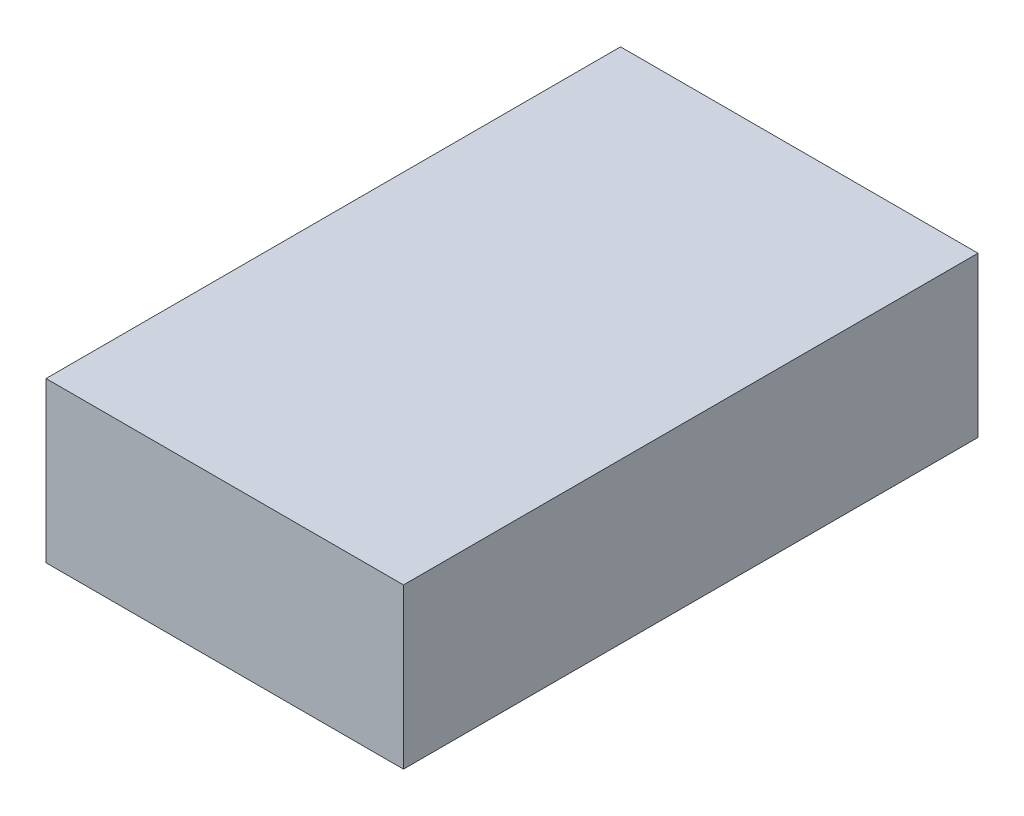
from build123d import *

# Parameters (mm, degrees)
SKETCH1_W           = 71.12
SKETCH1_H           = 31.75
BOSS_EXTRUDE1_DEPTH = 114.3


with BuildPart() as part:
    # Sketch1 → Boss-Extrude1 (new body)
    with BuildSketch(Plane.XY):
        with Locations((35.56, 15.875)):
            Rectangle(SKETCH1_W, SKETCH1_H)
    extrude(amount=BOSS_EXTRUDE1_DEPTH)


solid = part.part
